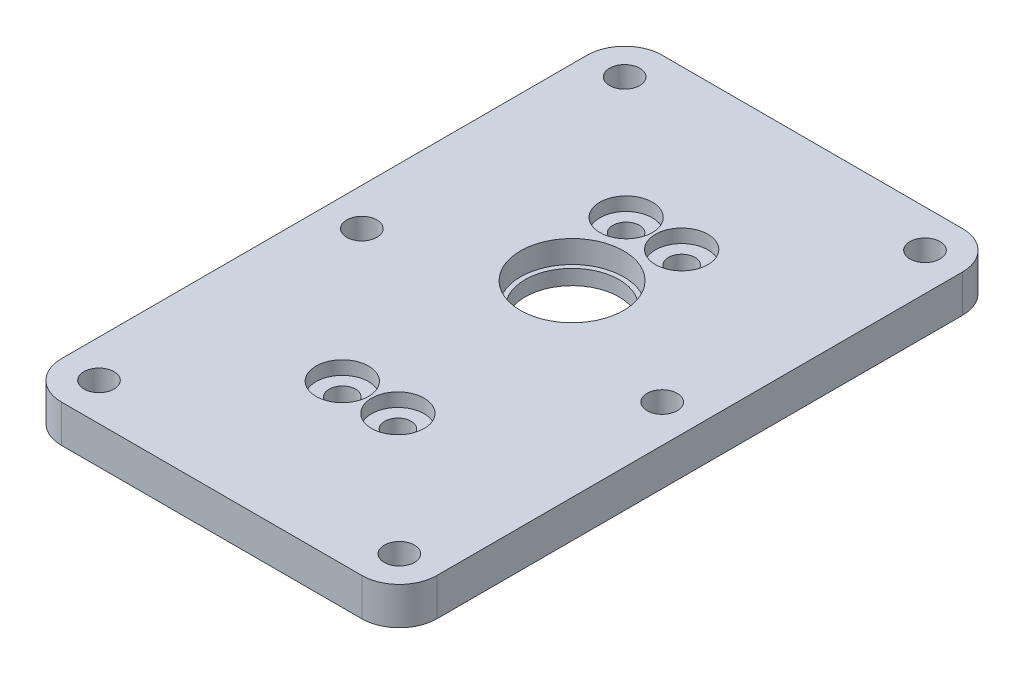
from build123d import *

# Parameters (mm, degrees)
SKETCH1_W              = 63.5
SKETCH1_H              = 101.6
BOSS_EXTRUDE1_DEPTH    = 6.35
SKETCH3_R              = 8.73125
CUT_EXTRUDE1_DEPTH     = 3.81
F_8_CLEARANCE_HOLE2_D  = 4.4958
SKETCH4_R              = 7.9375
CUT_EXTRUDE2_DEPTH     = 7.9375
FILLET1_R              = 6.35
F_10_CLEARANCE_HOLE1_D = 5.1054
CUT_EXTRUDE3_DEPTH     = 3.175
FILLET2_R              = 3.175
SKETCH11_R             = 4.445
CUT_EXTRUDE4_DEPTH     = 2.286


with BuildPart() as part:
    # Sketch1 → Boss-Extrude1 (new body)
    with BuildSketch(Plane(origin=(0, 0, 0), x_dir=(1, 0, 0), z_dir=(0, 1, 0))):
        Rectangle(SKETCH1_W, SKETCH1_H)
    extrude(amount=BOSS_EXTRUDE1_DEPTH)

    # Sketch3 → Cut-Extrude1 (cut)
    with BuildSketch(Plane(origin=(0, 6.35, 0), x_dir=(1, 0, 0), z_dir=(0, 1, 0))):
        with Locations((0, 10.16)):
            Circle(SKETCH3_R)
    extrude(amount=-CUT_EXTRUDE1_DEPTH, mode=Mode.SUBTRACT)

    # #8 Clearance Hole2 (through all)
    with Locations(Plane(origin=(0, 0, 0), x_dir=(-1, 0, 0), z_dir=(0, -1, 0))):
        with Locations((-4.7, 24.00000002), (4.7, -23.99999998), (4.7, 24.00000002), (-4.7, -23.99999998)):
            Hole(F_8_CLEARANCE_HOLE2_D / 2)

    # Sketch4 → Cut-Extrude2 (cut)
    with BuildSketch(Plane.XZ):
        with Locations((0, -10.16)):
            Circle(SKETCH4_R)
    extrude(amount=-CUT_EXTRUDE2_DEPTH, mode=Mode.SUBTRACT)

    # Fillet1
    fillet1_edges = [part.edges().sort_by_distance(p)[0] for p in [
        (-31.75, 3.175, -50.8),
        (31.75, 3.175, -50.8),
        (31.75, 3.175, 50.8),
        (-31.75, 3.175, 50.8),
    ]]
    fillet(fillet1_edges, radius=FILLET1_R)

    # #10 Clearance Hole1 (through all)
    with Locations(Plane(origin=(0, 6.35, 0), x_dir=(1, 0, 0), z_dir=(0, 1, 0))):
        with Locations((25.4, 44.45), (-25.4, 44.45), (-25.4, -44.45), (25.4, -44.45), (-25.4, 0), (25.4, 0)):
            Hole(F_10_CLEARANCE_HOLE1_D / 2)

    # Sketch10 → Cut-Extrude3 (cut)
    with BuildSketch(Plane.XZ):
        with BuildLine():
            Line((19.05, -44.45), (-19.05, -44.45))
            ThreePointArc((-19.05, -44.45), (-20.909871939, -39.959871939), (-25.4, -38.1))
            Line((-25.4, -38.1), (-25.4, -6.35))
            ThreePointArc((-25.4, -6.35), (-19.05, 0), (-25.4, 6.35))
            Line((-25.4, 6.35), (-25.4, 38.1))
            ThreePointArc((-25.4, 38.1), (-20.909871939, 39.959871939), (-19.05, 44.45))
            Line((-19.05, 44.45), (19.05, 44.45))
            ThreePointArc((19.05, 44.45), (20.909871939, 39.959871939), (25.4, 38.1))
            Line((25.4, 38.1), (25.4, 6.35))
            ThreePointArc((25.4, 6.35), (19.05, 0), (25.4, -6.35))
            Line((25.4, -6.35), (25.4, -38.1))
            ThreePointArc((25.4, -38.1), (20.909871939, -39.959871939), (19.05, -44.45))
        make_face()
        with BuildLine():
            ThreePointArc((0, -24.769029441), (7.830394623, -27.589155318), (6.100677898, -19.448131428))
            ThreePointArc((6.100677898, -19.448131428), (0, 0.9525), (-6.100677898, -19.448131428))
            ThreePointArc((-6.100677898, -19.448131428), (-7.830394623, -27.589155318), (0, -24.769029441))
        make_face(mode=Mode.SUBTRACT)
        with BuildLine():
            ThreePointArc((0, 23.230970559), (9.4625, 23.99999998), (0, 24.769029401))
            ThreePointArc((0, 24.769029401), (-9.4625, 23.99999998), (0, 23.230970559))
        make_face(mode=Mode.SUBTRACT)
    extrude(amount=-CUT_EXTRUDE3_DEPTH, mode=Mode.SUBTRACT)

    # Fillet2
    fillet2_edges = [part.edges().sort_by_distance(p)[0] for p in [
        (25.4, 1.5875, -38.1),
        (19.05, 1.5875, -44.45),
        (-19.05, 1.5875, -44.45),
        (-25.4, 1.5875, -38.1),
        (-25.4, 1.5875, -6.35),
        (-25.4, 1.5875, 6.35),
        (-25.4, 1.5875, 38.1),
        (-19.05, 1.5875, 44.45),
        (19.05, 1.5875, 44.45),
        (25.4, 1.5875, 38.1),
        (25.4, 1.5875, 6.35),
        (25.4, 1.5875, -6.35),
        (-6.100677898, 1.5875, -19.448131428),
        (6.100677898, 1.5875, -19.448131428),
        (0, 1.5875, -24.769029441),
        (0, 1.5875, 24.769029401),
        (0, 1.5875, 23.230970559),
    ]]
    fillet(fillet2_edges, radius=FILLET2_R)

    # Sketch11 → Cut-Extrude4 (cut)
    with BuildSketch(Plane(origin=(0, 6.35, 0), x_dir=(1, 0, 0), z_dir=(0, 1, 0))):
        with Locations((4.7, -23.99999998)):
            Circle(SKETCH11_R)
        with Locations((-4.7, -23.99999998)):
            Circle(SKETCH11_R)
        with Locations((4.7, 24.00000002)):
            Circle(SKETCH11_R)
        with Locations((-4.7, 24.00000002)):
            Circle(SKETCH11_R)
    extrude(amount=-CUT_EXTRUDE4_DEPTH, mode=Mode.SUBTRACT)


solid = part.part
